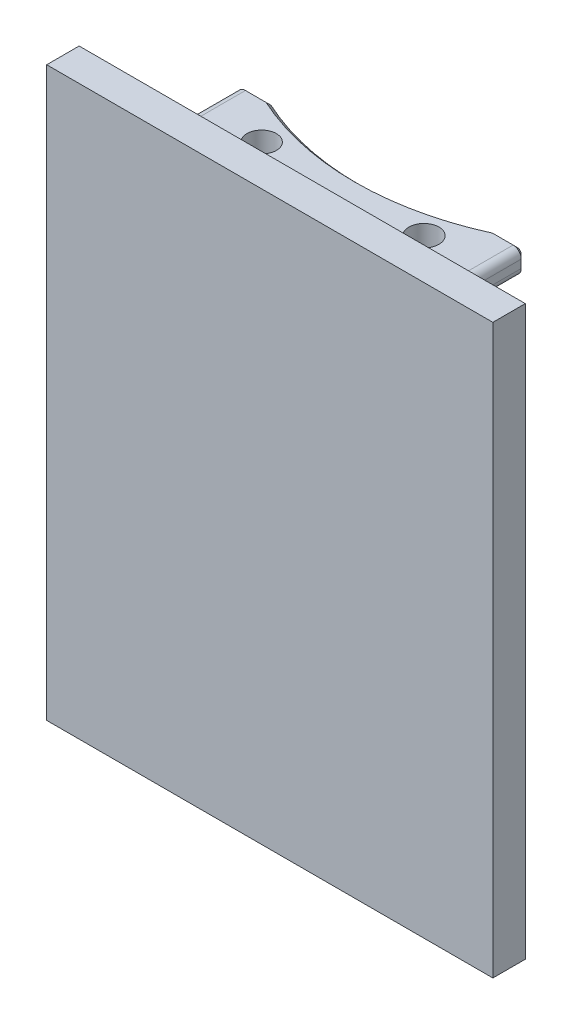
from build123d import *

# Parameters (mm, degrees)
SKETCH1_W               = 55
SKETCH1_H               = 70
BOSS_EXTRUDE1_DEPTH     = 4
BOSS_EXTRUDE2_DEPTH     = 10
SKETCH3_R               = 1.807722862
SKETCH3_R_2             = 1.85
CUT_EXTRUDE1_DEPTH      = 5
CUT_EXTRUDE1_DEPTH_BACK = 67
SKETCH4_R               = 2.1
CUT_EXTRUDE2_DEPTH      = 5
CUT_EXTRUDE2_DEPTH_BACK = 3
CUT_EXTRUDE3_START      = -46
SKETCH4_2_R             = 2.1
CUT_EXTRUDE3_DEPTH      = 3
CHAMFER1_SIZE           = 0.5
SKETCH5_R               = 33.04
CUT_EXTRUDE4_DEPTH      = 62
CHAMFER2_SIZE           = 0.5


with BuildPart() as part:
    # Sketch1 → Boss-Extrude1 (new body)
    with BuildSketch(Plane.XY):
        Rectangle(SKETCH1_W, SKETCH1_H)
    extrude(amount=BOSS_EXTRUDE1_DEPTH)

    # Sketch2 → Boss-Extrude2 (add)
    with BuildSketch(Plane(origin=(0, 0, 0), x_dir=(-1, 0, 0), z_dir=(0, 0, -1))):
        with BuildLine():
            Line((-16.5, 28), (16.5, 28))
            ThreePointArc((16.5, 28), (17.207106781, 28.292893219), (17.5, 29))
            Line((17.5, 29), (17.5, 30))
            ThreePointArc((17.5, 30), (17.207106781, 30.707106781), (16.5, 31))
            Line((16.5, 31), (-16.5, 31))
            ThreePointArc((-16.5, 31), (-17.207106781, 30.707106781), (-17.5, 30))
            Line((-17.5, 30), (-17.5, 29))
            ThreePointArc((-17.5, 29), (-17.207106781, 28.292893219), (-16.5, 28))
        make_face()
        with BuildLine():
            Line((-16.5, 18), (16.5, 18))
            ThreePointArc((16.5, 18), (17.207106781, 17.707106781), (17.5, 17))
            Line((17.5, 17), (17.5, 16))
            ThreePointArc((17.5, 16), (17.207106781, 15.292893219), (16.5, 15))
            Line((16.5, 15), (-16.5, 15))
            ThreePointArc((-16.5, 15), (-17.207106781, 15.292893219), (-17.5, 16))
            Line((-17.5, 16), (-17.5, 17))
            ThreePointArc((-17.5, 17), (-17.207106781, 17.707106781), (-16.5, 18))
        make_face()
        with BuildLine():
            Line((-16.5, -31), (16.5, -31))
            ThreePointArc((16.5, -31), (17.207106781, -30.707106781), (17.5, -30))
            Line((17.5, -30), (17.5, -29))
            ThreePointArc((17.5, -29), (17.207106781, -28.292893219), (16.5, -28))
            Line((16.5, -28), (-16.5, -28))
            ThreePointArc((-16.5, -28), (-17.207106781, -28.292893219), (-17.5, -29))
            Line((-17.5, -29), (-17.5, -30))
            ThreePointArc((-17.5, -30), (-17.207106781, -30.707106781), (-16.5, -31))
        make_face()
        with BuildLine():
            Line((-16.5, -15), (16.5, -15))
            ThreePointArc((16.5, -15), (17.207106781, -15.292893219), (17.5, -16))
            Line((17.5, -16), (17.5, -17))
            ThreePointArc((17.5, -17), (17.207106781, -17.707106781), (16.5, -18))
            Line((16.5, -18), (-16.5, -18))
            ThreePointArc((-16.5, -18), (-17.207106781, -17.707106781), (-17.5, -17))
            Line((-17.5, -17), (-17.5, -16))
            ThreePointArc((-17.5, -16), (-17.207106781, -15.292893219), (-16.5, -15))
        make_face()
    extrude(amount=BOSS_EXTRUDE2_DEPTH)

    # Sketch3 → Cut-Extrude1 (cut, two sides)
    with BuildSketch(Plane.XZ.offset(31)) as cut_extrude1_sk:
        with Locations((-10, -5)):
            Circle(SKETCH3_R)
        with Locations((10, -5)):
            Circle(SKETCH3_R_2)
    extrude(amount=CUT_EXTRUDE1_DEPTH, mode=Mode.SUBTRACT)
    extrude(cut_extrude1_sk.sketch, amount=-CUT_EXTRUDE1_DEPTH_BACK, mode=Mode.SUBTRACT)

    # Sketch4 → Cut-Extrude2 (cut, two sides)
    with BuildSketch(Plane.XZ.offset(31)) as cut_extrude2_sk:
        with Locations((10, -5)):
            Circle(SKETCH4_R)
        with Locations((-10, -5)):
            Circle(SKETCH4_R)
    extrude(amount=CUT_EXTRUDE2_DEPTH, mode=Mode.SUBTRACT)
    extrude(cut_extrude2_sk.sketch, amount=-CUT_EXTRUDE2_DEPTH_BACK, mode=Mode.SUBTRACT)

    # Sketch4_2 → Cut-Extrude3 (cut)
    with BuildSketch(Plane.XZ.offset(31).offset(CUT_EXTRUDE3_START)):
        with Locations((10, -5)):
            Circle(SKETCH4_2_R)
        with Locations((-10, -5)):
            Circle(SKETCH4_2_R)
    extrude(amount=-CUT_EXTRUDE3_DEPTH, mode=Mode.SUBTRACT)

    # Chamfer1
    chamfer1_edges = [part.edges().sort_by_distance(p)[0] for p in [
        (17.207106781, 17.707106781, -10),
        (17.5, 16.5, -10),
        (17.207106781, 15.292893219, -10),
        (0, 15, -10),
        (-17.207106781, 15.292893219, -10),
        (-17.5, 16.5, -10),
        (-17.207106781, 17.707106781, -10),
        (0, 18, -10),
        (-17.207106781, 30.707106781, -10),
        (0, 31, -10),
        (17.207106781, 30.707106781, -10),
        (17.5, 29.5, -10),
        (17.207106781, 28.292893219, -10),
        (0, 28, -10),
        (-17.207106781, 28.292893219, -10),
        (-17.5, 29.5, -10),
        (-17.207106781, -30.707106781, -10),
        (-17.5, -29.5, -10),
        (-17.207106781, -28.292893219, -10),
        (0, -28, -10),
        (17.207106781, -28.292893219, -10),
        (17.5, -29.5, -10),
        (17.207106781, -30.707106781, -10),
        (0, -31, -10),
        (-17.207106781, -15.292893219, -10),
        (0, -15, -10),
        (17.207106781, -15.292893219, -10),
        (17.5, -16.5, -10),
        (17.207106781, -17.707106781, -10),
        (0, -18, -10),
        (-17.207106781, -17.707106781, -10),
        (-17.5, -16.5, -10),
    ]]
    chamfer(chamfer1_edges, length=CHAMFER1_SIZE)

    # Sketch5 → Cut-Extrude4 (cut)
    with BuildSketch(Plane(origin=(0, 31, 0), x_dir=(1, 0, 0), z_dir=(0, 1, 0))):
        with Locations((0, 40)):
            Circle(SKETCH5_R)
    extrude(amount=-CUT_EXTRUDE4_DEPTH, mode=Mode.SUBTRACT)

    # Chamfer2
    chamfer2_edges = [part.edges().sort_by_distance(p)[0] for p in [
        (0, -31, -6.96),
        (0, -28, -6.96),
        (0, -18, -6.96),
        (0, -15, -6.96),
        (0, 15, -6.96),
        (0, 18, -6.96),
        (0, 28, -6.96),
        (0, 31, -6.96),
    ]]
    chamfer(chamfer2_edges, length=CHAMFER2_SIZE)


solid = part.part
